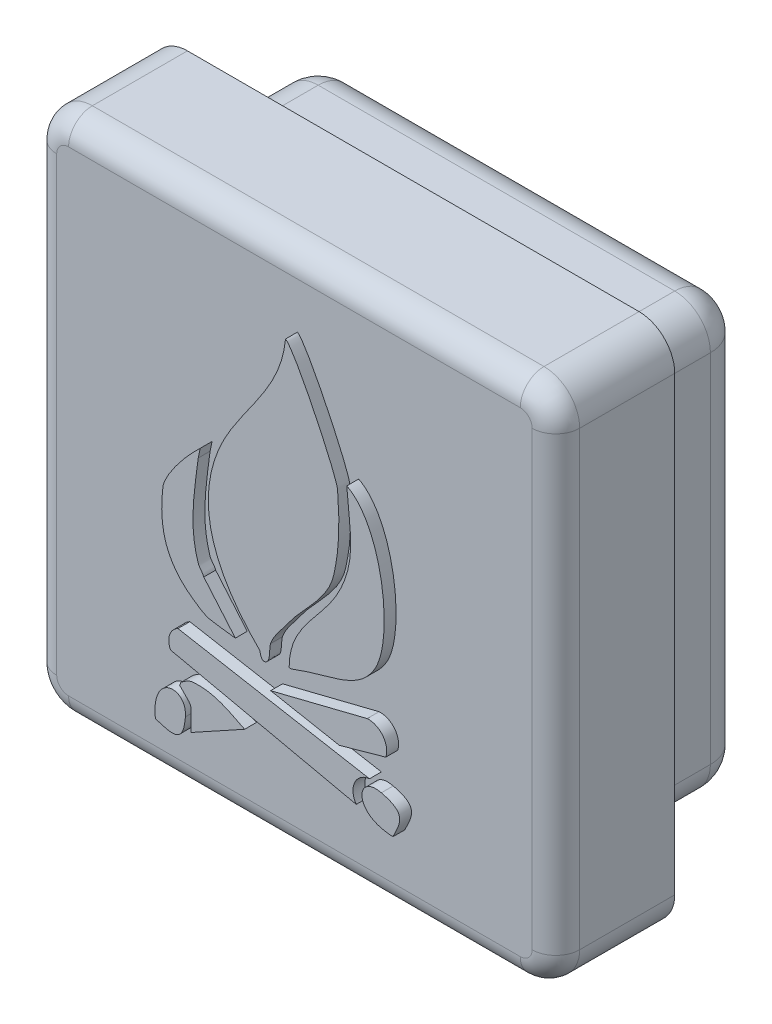
from build123d import *

# Parameters (mm, degrees)
ESQUISSE2_W             = 44
ESQUISSE2_H             = 44
BOSS_EXTRU_1_DEPTH      = 10
ESQUISSE3_W             = 36
ESQUISSE3_H             = 36
BOSS_EXTRU_2_DEPTH      = 10
ESQUISSE4_W             = 42.5
ESQUISSE4_H             = 42.5
ESQUISSE4_W_2           = 36
ESQUISSE4_H_2           = 36
ENL_V_MAT_EXTRU_1_DEPTH = 5
CONG_1_R                = 3
CONG_2_R                = 2
BOSS_EXTRU_4_DEPTH      = 1


with BuildPart() as part:
    # Esquisse2 → Boss.-Extru.1 (new body)
    with BuildSketch(Plane.XY):
        with Locations((22, 22)):
            Rectangle(ESQUISSE2_W, ESQUISSE2_H)
    extrude(amount=BOSS_EXTRU_1_DEPTH)

    # Esquisse3 → Boss.-Extru.2 (add)
    with BuildSketch(Plane(origin=(0, 0, 0), x_dir=(-1, 0, 0), z_dir=(0, 0, -1))):
        with Locations((-22, 22)):
            Rectangle(ESQUISSE3_W, ESQUISSE3_H)
    extrude(amount=BOSS_EXTRU_2_DEPTH)

    # Esquisse4 → Enlèv. mat.-Extru.1 (cut)
    with BuildSketch(Plane(origin=(0, 0, 0), x_dir=(-1, 0, 0), z_dir=(0, 0, -1))):
        with Locations((-21.25, 21.25)):
            Rectangle(ESQUISSE4_W, ESQUISSE4_H)
        with Locations((-22, 22)):
            Rectangle(ESQUISSE4_W_2, ESQUISSE4_H_2, mode=Mode.SUBTRACT)
    extrude(amount=-ENL_V_MAT_EXTRU_1_DEPTH, mode=Mode.SUBTRACT)

    # Congé1
    cong_1_edges = [part.edges().sort_by_distance(p)[0] for p in [
        (22, 40, -10),
        (4, 22, -10),
        (22, 4, -10),
        (40, 22, -10),
        (44, 0, 5),
        (44, 44, 5),
        (0, 0, 7.5),
        (0, 44, 5),
        (4, 4, -2.5),
        (4, 40, -2.5),
        (40, 4, -2.5),
        (40, 40, -2.5),
        (42.5, 42.5, 2.5),
    ]]
    fillet(cong_1_edges, radius=CONG_1_R)

    # Congé2
    cong_2_edges = [part.edges().sort_by_distance(p)[0] for p in [
        (44, 22, 10),
        (22, 0, 10),
        (0, 22, 10),
        (22, 44, 10),
        (0.878679656, 43.121320344, 10),
        (0.878679656, 0.878679656, 10),
        (43.121320344, 43.121320344, 10),
        (43.121320344, 0.878679656, 10),
    ]]
    fillet(cong_2_edges, radius=CONG_2_R)

    # Esquisse7 → Boss.-Extru.4 (add)
    with BuildSketch(Plane.XY.offset(10)):
        with BuildLine():
            Line((15.374098957, 17.346843443), (18.030348957, 14.221843443))
            add(Edge.make_bspline(
                [(18.030348957, 14.221843443), (17.301182291, 14.32601011), (16.565114838, 14.389890267), (15.842848957, 14.534343443), (15.423010802, 14.618311074), (14.838115665, 15.028795794), (14.436598957, 15.315593443), (12.049681404, 17.020534553), (11.595795075, 19.293760446), (11.936598957, 22.190593443), (12.054157826, 23.189843826), (13.69238751, 25.196381996), (14.436598957, 25.940593443)],
                knots=[0, 0, 0, 0, 1, 1, 1, 2, 2, 2, 3, 3, 3, 4, 4, 4, 4], degree=3))
            Line((14.436598957, 25.940593443), (15.06939707, 26.573391556))
            Line((15.06939707, 26.573391556), (14.905348957, 25.784343443))
            add(Edge.make_bspline(
                [(14.905348957, 25.784343443), (14.590446041, 23.265120116), (14.091309116, 20.570212966), (14.905348957, 18.128093443), (15.001385879, 17.839982679), (15.278062036, 17.634954207), (15.374098957, 17.346843443)],
                knots=[0, 0, 0, 0, 1, 1, 1, 2, 2, 2, 2], degree=3))
        make_face()
        with BuildLine():
            Line((30.686598957, 11.878093443), (26.780348957, 10.784343443))
            Line((26.780348957, 10.784343443), (20.999098957, 11.878093443))
            Line((20.999098957, 11.878093443), (29.124098957, 13.909343443))
            ThreePointArc((29.124098957, 13.909343443), (30.444920086, 13.308773157), (30.686598957, 11.878093443))
        make_face()
        with BuildLine():
            Line((18.811598957, 7.971843443), (14.280348957, 5.471843443))
            add(Edge.make_bspline(
                [(14.280348957, 5.471843443), (14.280348957, 7.772797666), (14.593726557, 7.189715843), (13.342848957, 8.440593443)],
                knots=[0, 0, 0, 0, 1, 1, 1, 1], degree=3))
            add(Edge.make_bspline(
                [(13.342848957, 8.440593443), (13.394932291, 8.54476011), (13.404330032, 8.685401354), (13.499098957, 8.753093443), (13.783405732, 8.956169711), (14.089133052, 9.185268084), (14.436598957, 9.221843443), (16.134694919, 9.400590386), (17.384797269, 8.685244287), (18.811598957, 7.971843443)],
                knots=[0, 0, 0, 0, 1, 1, 1, 2, 2, 2, 3, 3, 3, 3], degree=3))
        make_face()
        with BuildLine():
            Line((13.200641117, 12.506283222), (29.317230938, 9.618393711))
            ThreePointArc((29.317230938, 9.618393711), (28.067553161, 8.724486443), (28.200641117, 7.193783222))
            Line((28.200641117, 7.193783222), (12.575641117, 10.631283222))
            ThreePointArc((12.575641117, 10.631283222), (12.499815902, 11.698224961), (13.200641117, 12.506283222))
        make_face()
        with BuildLine():
            add(Edge.make_bspline(
                [(20.999098957, 15.315593443), (20.827145061, 14.799731755), (21.046210645, 13.925047339), (20.530348957, 13.753093443), (20.153128088, 13.627353153), (20.137873233, 14.301819167), (20.061598957, 14.378093443), (16.567694762, 17.871997638), (14.613515541, 21.933204334), (16.467848957, 26.878093443), (17.971713728, 30.888399498), (21.846423142, 33.698659479), (22.249098957, 38.128093443)],
                knots=[4, 4, 4, 4, 5, 5, 5, 6, 6, 6, 7, 7, 7, 8, 8, 8, 8], degree=3))
            add(Edge.make_bspline(
                [(22.249098957, 38.128093443), (23.024720103, 37.74028287), (26.549972992, 30.317022339), (26.624098957, 29.378093443), (26.824723104, 26.836854256), (26.793735434, 25.141457588), (26.311598957, 22.971843443), (25.843661476, 20.866124777), (23.763276375, 19.341691827), (22.561598957, 17.659343443), (22.093633816, 17.004192245), (21.257183639, 16.089847489), (20.999098957, 15.315593443)],
                knots=[0, 0, 0, 0, 1, 1, 1, 2, 2, 2, 3, 3, 3, 4, 4, 4, 4], degree=3))
        make_face()
        with BuildLine():
            add(Edge.make_bspline(
                [(22.874098957, 14.378093443), (22.776875457, 14.340699789), (22.561598957, 14.273926776), (22.561598957, 14.378093443), (22.561598957, 17.724570677), (25.385181625, 19.244008778), (26.780348957, 22.034343443), (28.269529967, 25.012705463), (27.627114524, 26.898375507), (27.405348957, 30.003093443)],
                knots=[3, 3, 3, 3, 4, 4, 4, 5, 5, 5, 6, 6, 6, 6], degree=3))
            add(Edge.make_bspline(
                [(27.405348957, 30.003093443), (30.439237099, 28.486149372), (31.410808057, 20.585108609), (29.749098957, 17.815593443), (28.578255605, 15.864187855), (26.718288261, 15.58655694), (24.749098957, 15.003093443), (24.117435238, 14.815933822), (23.488994366, 14.614591677), (22.874098957, 14.378093443)],
                knots=[0, 0, 0, 0, 1, 1, 1, 2, 2, 2, 3, 3, 3, 3], degree=3))
        make_face()
        with BuildLine():
            add(Edge.make_bspline(
                [(13.825641117, 6.383595142), (13.664946359, 4.294397314), (12.835062605, 4.491118619), (11.307669526, 4.983380758)],
                knots=[1, 1, 1, 1, 2, 2, 2, 2], degree=3))
            add(Edge.make_bspline(
                [(11.307669526, 4.983380758), (10.888236852, 8.443524348), (13.995704046, 8.594588879), (13.825641117, 6.383595142)],
                knots=[0, 0, 0, 0, 1, 1, 1, 1], degree=3))
        make_face()
        with BuildLine():
            add(Edge.make_bspline(
                [(30.312986898, 9.093826211), (32.34922339, 8.599547626), (32.02172038, 7.812052803), (31.290447284, 6.383595142)],
                knots=[1, 1, 1, 1, 2, 2, 2, 2], degree=3))
            add(Edge.make_bspline(
                [(31.290447284, 6.383595142), (27.807867011, 6.525553152), (28.158042034, 9.616920214), (30.312986898, 9.093826211)],
                knots=[0, 0, 0, 0, 1, 1, 1, 1], degree=3))
        make_face()
    extrude(amount=BOSS_EXTRU_4_DEPTH)


solid = part.part
